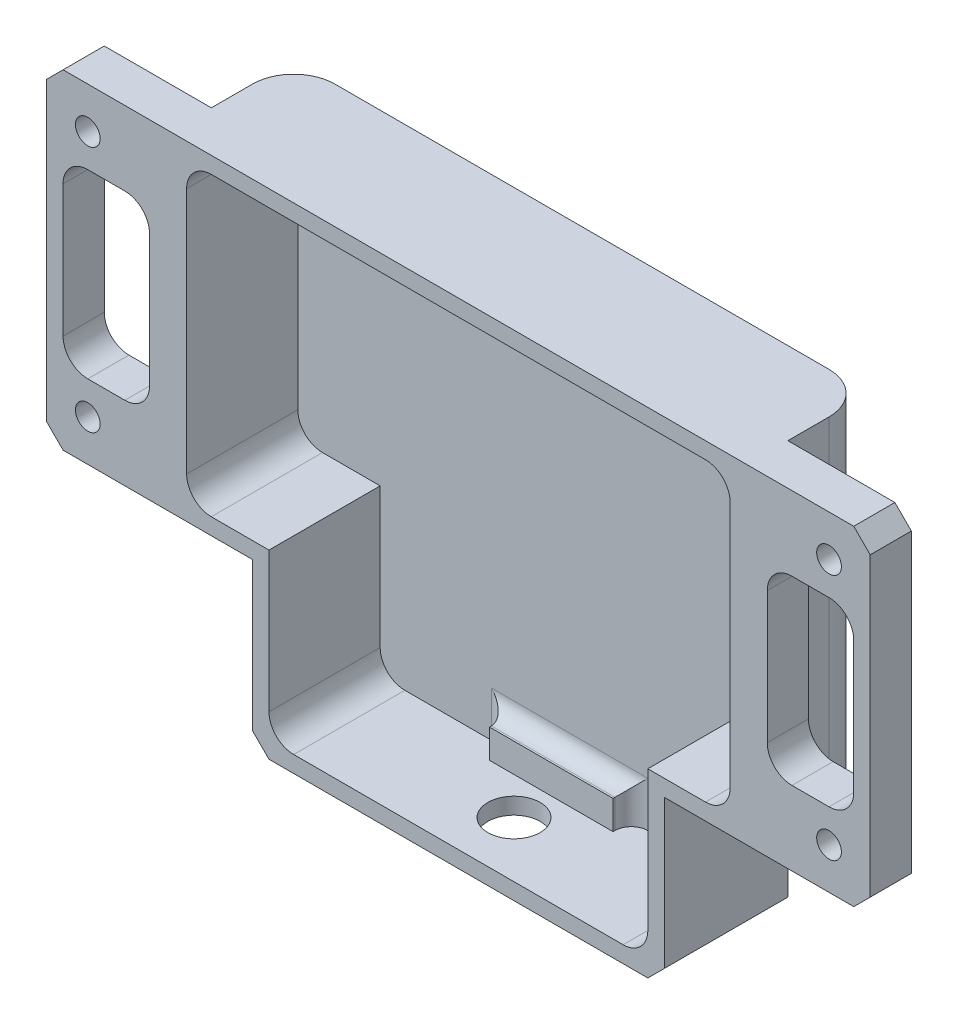
from build123d import *

# Parameters (mm, degrees)
AUFSATZ_LINEAR_AUSTRAGEN1_DEPTH      = 2.5
AUFSATZ_LINEAR_AUSTRAGEN1_DEPTH_BACK = 2.5
SKIZZE2_R                            = 1.5
SCHNITT_LINEAR_AUSTRAGEN1_DEPTH      = 3.5
SCHNITT_LINEAR_AUSTRAGEN1_DEPTH_BACK = 3.5
SCHNITT_LINEAR_AUSTRAGEN2_DEPTH      = 3.5
SCHNITT_LINEAR_AUSTRAGEN2_DEPTH_BACK = 3.5
SKIZZE7_W                            = 50
SKIZZE7_H                            = 20
AUFSATZ_LINEAR_AUSTRAGEN3_DEPTH      = 10
SCHNITT_LINEAR_AUSTRAGEN6_DEPTH      = 13.5
FASE1_SIZE                           = 2
SKETCH1_R                            = 3.175
CUT_EXTRUDE1_DEPTH                   = 10
SKETCH2_W                            = 15
SKETCH2_H                            = 3.5
BOSS_EXTRUDE1_DEPTH                  = 2.225
FILLET2_R                            = 5
FILLET1_R                            = 2


with BuildPart() as part:
    # Skizze1 → Aufsatz-Linear austragen1 (new body, two sides)
    with BuildSketch(Plane.XY) as aufsatz_linear_austragen1_sk:
        Polygon((-50, -20), (-50, 20), (50, 20), (50, -20), (25, -20), (25, -40), (-25, -40), (-25, -20), align=None)
    extrude(amount=AUFSATZ_LINEAR_AUSTRAGEN1_DEPTH)
    extrude(aufsatz_linear_austragen1_sk.sketch, amount=-AUFSATZ_LINEAR_AUSTRAGEN1_DEPTH_BACK)

    # Skizze2 → Schnitt-Linear austragen1 (cut, two sides)
    with BuildSketch(Plane.XY) as schnitt_linear_austragen1_sk:
        with Locations((-45, 15)):
            Circle(SKIZZE2_R)
        with Locations((-45, -15)):
            Circle(SKIZZE2_R)
        with Locations((45, -15)):
            Circle(SKIZZE2_R)
        with Locations((45, 15)):
            Circle(SKIZZE2_R)
    extrude(amount=SCHNITT_LINEAR_AUSTRAGEN1_DEPTH, mode=Mode.SUBTRACT)
    extrude(schnitt_linear_austragen1_sk.sketch, amount=-SCHNITT_LINEAR_AUSTRAGEN1_DEPTH_BACK, mode=Mode.SUBTRACT)

    # Skizze4 → Schnitt-Linear austragen2 (cut, two sides)
    with BuildSketch(Plane.XY) as schnitt_linear_austragen2_sk:
        with BuildLine():
            Line((-48, -8), (-48, 8))
            ThreePointArc((-48, 8), (-47.121320344, 10.121320344), (-45, 11))
            Line((-45, 11), (-40.5, 11))
            ThreePointArc((-40.5, 11), (-38.378679656, 10.121320344), (-37.5, 8))
            Line((-37.5, 8), (-37.5, -8))
            ThreePointArc((-37.5, -8), (-38.378679656, -10.121320344), (-40.5, -11))
            Line((-40.5, -11), (-45, -11))
            ThreePointArc((-45, -11), (-47.121320344, -10.121320344), (-48, -8))
        make_face()
        with BuildLine():
            Line((45, -11), (40.5, -11))
            ThreePointArc((40.5, -11), (38.378679656, -10.121320344), (37.5, -8))
            Line((37.5, -8), (37.5, 8))
            ThreePointArc((37.5, 8), (38.378679656, 10.121320344), (40.5, 11))
            Line((40.5, 11), (45, 11))
            ThreePointArc((45, 11), (47.121320344, 10.121320344), (48, 8))
            Line((48, 8), (48, -8))
            ThreePointArc((48, -8), (47.121320344, -10.121320344), (45, -11))
        make_face()
    extrude(amount=SCHNITT_LINEAR_AUSTRAGEN2_DEPTH, mode=Mode.SUBTRACT)
    extrude(schnitt_linear_austragen2_sk.sketch, amount=-SCHNITT_LINEAR_AUSTRAGEN2_DEPTH_BACK, mode=Mode.SUBTRACT)

    # Skizze7 → Aufsatz-Linear austragen3 (add)
    with BuildSketch(Plane(origin=(0, 0, -2.5), x_dir=(-1, 0, 0), z_dir=(0, 0, -1))):
        with Locations((0, -30)):
            Rectangle(SKIZZE7_W, SKIZZE7_H)
        Polygon((35, 20), (-35, 20), (-35, -20), (-25, -20), (25, -20), (35, -20), align=None)
    extrude(amount=AUFSATZ_LINEAR_AUSTRAGEN3_DEPTH)

    # Skizze8 → Schnitt-Linear austragen6 (cut)
    with BuildSketch(Plane.XY.offset(2.5)):
        with BuildLine():
            Line((30, 18), (-30, 18))
            ThreePointArc((-30, 18), (-32.121320344, 17.121320344), (-33, 15))
            Line((-33, 15), (-33, -15))
            ThreePointArc((-33, -15), (-32.121320344, -17.121320344), (-30, -18))
            Line((-30, -18), (30, -18))
            ThreePointArc((30, -18), (32.121320344, -17.121320344), (33, -15))
            Line((33, -15), (33, 15))
            ThreePointArc((33, 15), (32.121320344, 17.121320344), (30, 18))
        make_face()
        with BuildLine():
            Line((23, -18), (-23, -18))
            Line((-23, -18), (-23, -35))
            ThreePointArc((-23, -35), (-22.121320344, -37.121320344), (-20, -38))
            Line((-20, -38), (20, -38))
            ThreePointArc((20, -38), (22.121320344, -37.121320344), (23, -35))
            Line((23, -35), (23, -18))
        make_face()
    extrude(amount=-SCHNITT_LINEAR_AUSTRAGEN6_DEPTH, mode=Mode.SUBTRACT)

    # Fase1
    fase1_edges = [part.edges().sort_by_distance(p)[0] for p in [
        (-50, -20, 0),
        (-50, 20, 0),
        (50, 20, 0),
        (50, -20, 0),
        (25, -40, -5),
        (-25, -40, -5),
    ]]
    chamfer(fase1_edges, length=FASE1_SIZE)

    # Sketch1 → Cut-Extrude1 (cut)
    with BuildSketch(Plane(origin=(0, -40, 0), x_dir=(1, 0, 0), z_dir=(0, 1, 0))):
        with Locations((0, 4.25)):
            Circle(SKETCH1_R)
    extrude(amount=CUT_EXTRUDE1_DEPTH, mode=Mode.SUBTRACT)

    # Sketch2 → Boss-Extrude1 (add)
    with BuildSketch(Plane.XY.offset(-11)):
        with Locations((0, -36.25)):
            Rectangle(SKETCH2_W, SKETCH2_H)
    extrude(amount=BOSS_EXTRUDE1_DEPTH)

    # Fillet2
    fillet2_edges = [part.edges().sort_by_distance(p)[0] for p in [
        (-35, 0, -12.5),
        (35, 0, -12.5),
    ]]
    fillet(fillet2_edges, radius=FILLET2_R)

    # Fillet1
    fillet1_edges = [part.edges().sort_by_distance(p)[0] for p in [
        (-7.5, -36.25, -11),
        (7.5, -36.25, -11),
        (0, -34.5, -11),
    ]]
    fillet(fillet1_edges, radius=FILLET1_R)


solid = part.part
